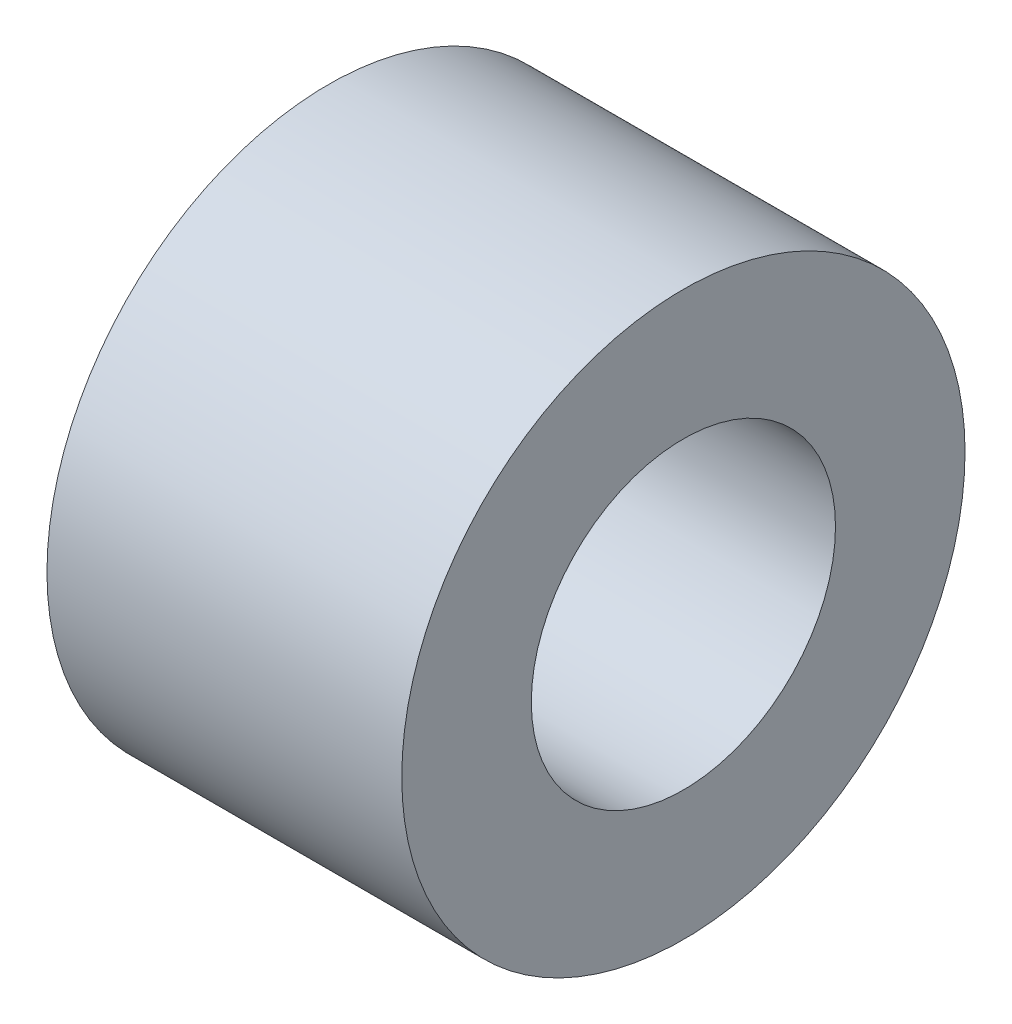
from build123d import *

# Parameters (mm, degrees)
ESQUISSE1_R        = 6.35
ESQUISSE1_R_2      = 3.429
BOSS_EXTRU_1_DEPTH = 8


with BuildPart() as part:
    # Esquisse1 → Boss.-Extru.1 (new body)
    with BuildSketch(Plane(origin=(0, 0, 0), x_dir=(0, 0, -1), z_dir=(1, 0, 0))):
        Circle(ESQUISSE1_R)
        Circle(ESQUISSE1_R_2, mode=Mode.SUBTRACT)
    extrude(amount=-BOSS_EXTRU_1_DEPTH)


solid = part.part
